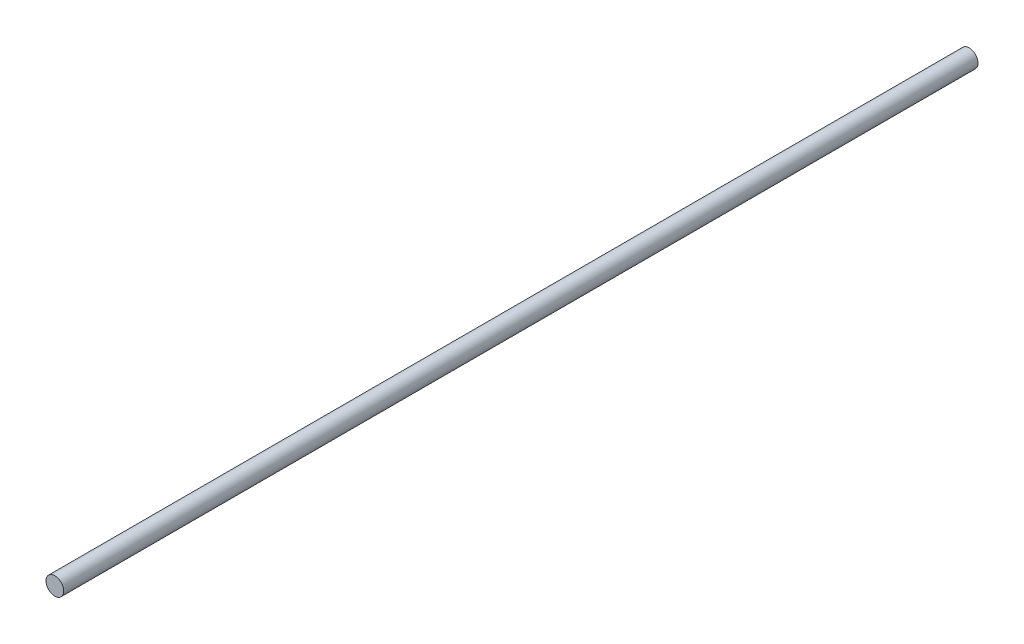
from build123d import *

# Parameters (mm, degrees)
SKETCH1_R           = 15
BOSS_EXTRUDE1_DEPTH = 1550


with BuildPart() as part:
    # Sketch1 → Boss-Extrude1 (new body)
    with BuildSketch(Plane.XY):
        Circle(SKETCH1_R)
    extrude(amount=BOSS_EXTRUDE1_DEPTH)


solid = part.part
